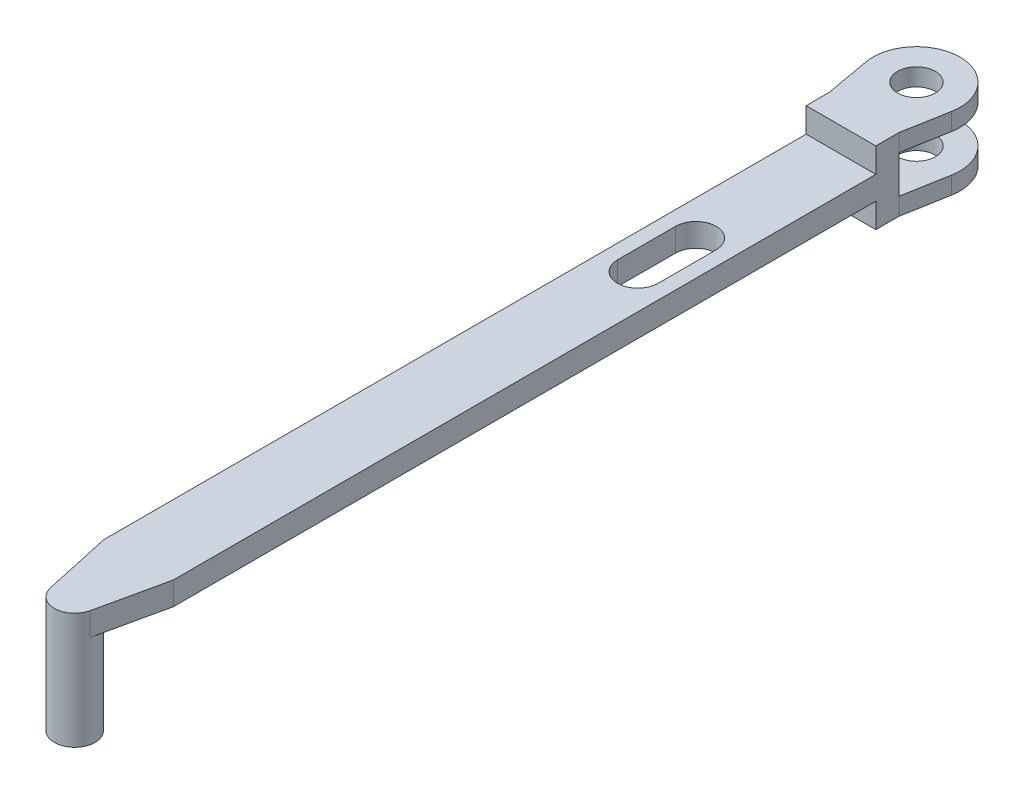
from build123d import *

# Parameters (mm, degrees)
EXTRUDE_1_DEPTH      = 3
SKETCH_2_W           = 12
SKETCH_2_H           = 12.5
EXTRUDE_2_DEPTH      = 4
EXTRUDE_3_DEPTH      = 3
SKETCH_4_R           = 3.25
CUT_EXTRUDE_1_DEPTH  = 13.5
EXTRUDE_4_DEPTH      = 2
EXTRUDE_4_DEPTH_BACK = 2
SKETCH_6_R           = 3.5
EXTRUDE_5_DEPTH      = 20


with BuildPart() as part:
    # Эскиз1 → Бобышка-Вытянуть1 (new body)
    with BuildSketch(Plane(origin=(0, 0, 0), x_dir=(1, 0, 0), z_dir=(0, 1, 0))):
        with BuildLine():
            Line((-7.38128575, -1.329142833), (-6, -9))
            Line((-6, -9), (6, -9))
            Line((6, -9), (7.38128575, -1.329142833))
            ThreePointArc((7.38128575, -1.329142833), (0, 7.5), (-7.38128575, -1.329142833))
        make_face()
    extrude(amount=EXTRUDE_1_DEPTH)

    # Эскиз2 → Бобышка-Вытянуть2 (add)
    with BuildSketch(Plane.XY.offset(9)):
        with Locations((0, 6.25)):
            Rectangle(SKETCH_2_W, SKETCH_2_H)
    extrude(amount=EXTRUDE_2_DEPTH)

    # Эскиз3 → Бобышка-Вытянуть3 (add)
    with BuildSketch(Plane(origin=(0, 12.5, 0), x_dir=(1, 0, 0), z_dir=(0, 1, 0))):
        with BuildLine():
            Line((-7.38128575, -1.329142833), (-6, -9))
            Line((-6, -9), (6, -9))
            Line((6, -9), (7.38128575, -1.329142833))
            ThreePointArc((7.38128575, -1.329142833), (0, 7.5), (-7.38128575, -1.329142833))
        make_face()
    extrude(amount=-EXTRUDE_3_DEPTH)

    # Эскиз4 → Вырез-Вытянуть1 (cut, through all)
    with BuildSketch(Plane(origin=(0, 12.5, 0), x_dir=(1, 0, 0), z_dir=(0, 1, 0))):
        Circle(SKETCH_4_R)
    extrude(amount=-CUT_EXTRUDE_1_DEPTH, mode=Mode.SUBTRACT)

    # Эскиз5 → Бобышка-Вытянуть4 (add, two sides)
    with BuildSketch(Plane(origin=(0, 6.25, 0), x_dir=(1, 0, 0), z_dir=(0, 1, 0))) as extrude_4_sk:
        with BuildLine():
            Line((-6, -13), (6, -13))
            Line((6, -13), (6, -134.006168685))
            Line((6, -134.006168685), (3.418398609, -145.751366054))
            ThreePointArc((3.418398609, -145.751366054), (0, -148.5), (-3.418398609, -145.751366054))
            Line((-3.418398609, -145.751366054), (-6, -134.006168685))
            Line((-6, -134.006168685), (-6, -13))
        make_face()
        with BuildLine():
            Line((3.5, -38), (3.5, -48))
            ThreePointArc((3.5, -48), (0, -51.5), (-3.5, -48))
            Line((-3.5, -48), (-3.5, -38))
            ThreePointArc((-3.5, -38), (0, -34.5), (3.5, -38))
        make_face(mode=Mode.SUBTRACT)
    extrude(amount=EXTRUDE_4_DEPTH)
    extrude(extrude_4_sk.sketch, amount=-EXTRUDE_4_DEPTH_BACK)

    # Эскиз6 → Бобышка-Вытянуть5 (add)
    with BuildSketch(Plane(origin=(0, 8.25, 0), x_dir=(1, 0, 0), z_dir=(0, 1, 0))):
        with Locations((0, -145)):
            Circle(SKETCH_6_R)
    extrude(amount=-EXTRUDE_5_DEPTH)


solid = part.part
